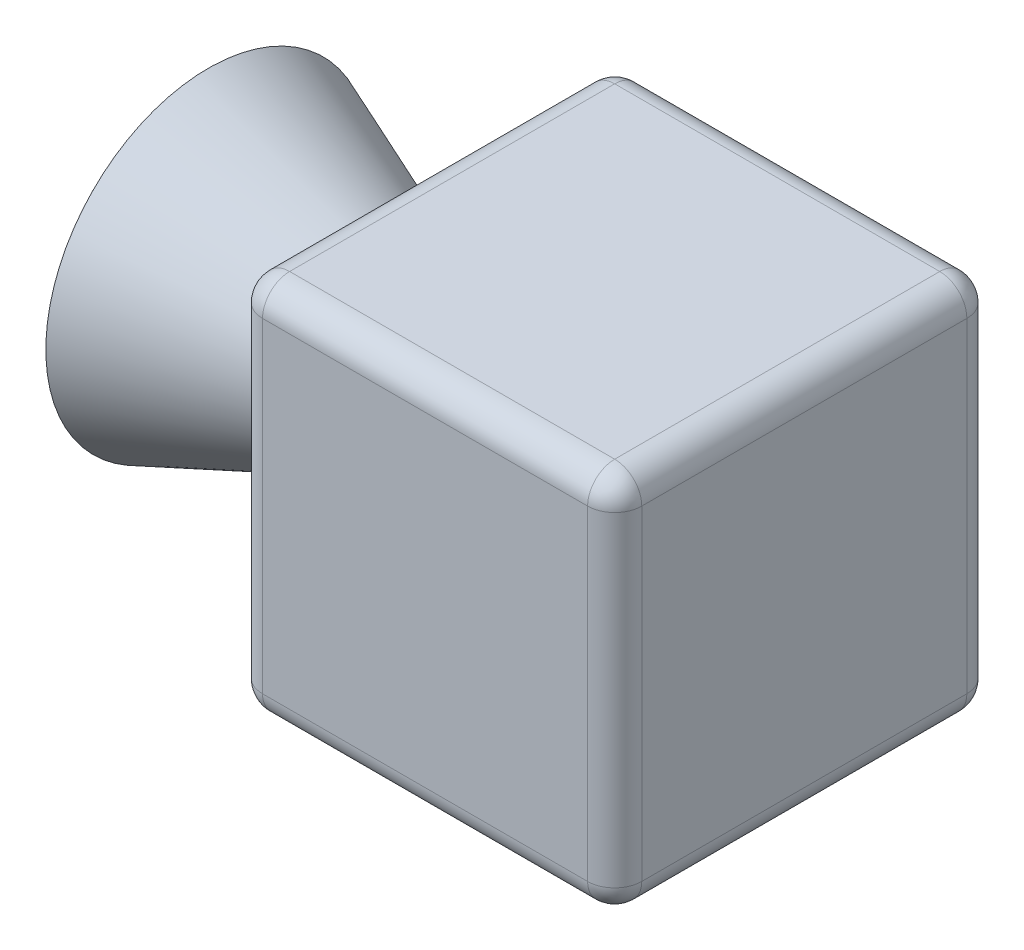
from build123d import *

# Parameters (mm, degrees)
AUFSATZ_LINEAR_AUSTRAGEN2_DEPTH = 7
VERRUNDUNG2_R                   = 1


with BuildPart() as part:
    # Skizze1 → Rotation1 (revolve)
    with BuildSketch(Plane(origin=(0, 0, 0), x_dir=(1, 0, 0), z_dir=(0, 1, 0))):
        with BuildLine():
            Line((-7, 0), (-7, 2.8))
            Line((-7, 2.8), (-15, 6))
            ThreePointArc((-15, 6), (-16.486832981, 3.16227766), (-17, 0))
            Line((-17, 0), (-7, 0))
        make_face()
    revolve(axis=Axis((-7.719127457, 0, 0), (-1, 0, 0)))

    # Skizze1_3 → Aufsatz-Linear austragen2 (add, symmetric)
    with BuildSketch(Plane(origin=(0, 0, 0), x_dir=(1, 0, 0), z_dir=(0, 1, 0))):
        Polygon((-7, 7), (-7, 2.8), (-7, 0), (-7, -7), (7, -7), (7, 0), (7, 7), align=None)
    extrude(amount=AUFSATZ_LINEAR_AUSTRAGEN2_DEPTH, both=True)

    # Verrundung2
    verrundung2_edges = [part.edges().sort_by_distance(p)[0] for p in [
        (-7, 7, 0),
        (7, 7, 0),
        (7, -7, 0),
        (-7, -7, 0),
        (-7, 0, 7),
        (0, 7, 7),
        (7, 0, 7),
        (0, -7, 7),
        (7, 0, -7),
        (0, 7, -7),
        (-7, 0, -7),
        (0, -7, -7),
    ]]
    fillet(verrundung2_edges, radius=VERRUNDUNG2_R)


solid = part.part
